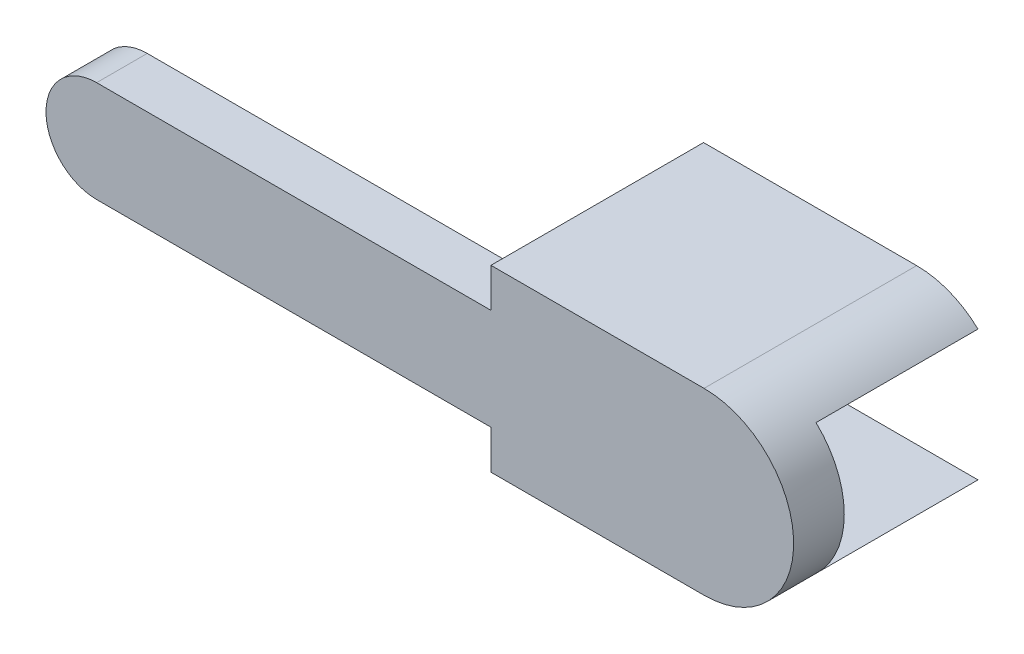
from build123d import *

# Parameters (mm, degrees)
BOSS_EXTRUDE1_DEPTH = 5
SKETCH2_R           = 2.35
CUT_EXTRUDE1_DEPTH  = 3
BOSS_EXTRUDE3_DEPTH = 5
BOSS_EXTRUDE4_DEPTH = 16
SKETCH5_R           = 1.025
CUT_EXTRUDE2_DEPTH  = 5


with BuildPart() as part:
    # Sketch1 → Boss-Extrude1 (new body)
    with BuildSketch(Plane.XY):
        with BuildLine():
            Line((0, 5), (60, 5))
            ThreePointArc((60, 5), (65, 0), (60, -5))
            Line((60, -5), (0, -5))
            ThreePointArc((0, -5), (-5, 0), (0, 5))
        make_face()
    extrude(amount=BOSS_EXTRUDE1_DEPTH)

    # Sketch2 → Cut-Extrude1 (cut)
    with BuildSketch(Plane(origin=(0, 0, 0), x_dir=(-1, 0, 0), z_dir=(0, 0, -1))):
        Circle(SKETCH2_R)
    extrude(amount=-CUT_EXTRUDE1_DEPTH, mode=Mode.SUBTRACT)

    # Sketch3 → Boss-Extrude3 (add)
    with BuildSketch(Plane.XY.offset(5)):
        with BuildLine():
            Line((38.95, -6.35), (38.95, 6.35))
            Line((38.95, 6.35), (38.95, 8.85))
            Line((38.95, 8.85), (60, 8.85))
            ThreePointArc((60, 8.85), (68.85, 0), (60, -8.85))
            Line((60, -8.85), (38.95, -8.85))
            Line((38.95, -8.85), (38.95, -6.35))
        make_face()
    extrude(amount=-BOSS_EXTRUDE3_DEPTH)

    # Sketch4 → Boss-Extrude4 (add)
    with BuildSketch(Plane(origin=(0, 0, 0), x_dir=(-1, 0, 0), z_dir=(0, 0, -1))):
        with BuildLine():
            Line((-60, 8.85), (-38.95, 8.85))
            Line((-38.95, 8.85), (-38.95, 5))
            Line((-38.95, 5), (-38.95, -5))
            Line((-38.95, -5), (-38.95, -8.85))
            Line((-38.95, -8.85), (-60, -8.85))
            ThreePointArc((-60, -8.85), (-63.258834147, -8.228152891), (-66.059702963, -6.45))
            Line((-66.059702963, -6.45), (-43.45, -6.45))
            Line((-43.45, -6.45), (-43.45, 6.45))
            Line((-43.45, 6.45), (-66.059702963, 6.45))
            ThreePointArc((-66.059702963, 6.45), (-63.258834147, 8.228152891), (-60, 8.85))
        make_face()
    extrude(amount=BOSS_EXTRUDE4_DEPTH)

    # Sketch5 → Cut-Extrude2 (cut)
    with BuildSketch(Plane(origin=(0, 0, -16), x_dir=(-1, 0, 0), z_dir=(0, 0, -1))):
        with Locations((-41.25, 0)):
            Circle(SKETCH5_R)
    extrude(amount=-CUT_EXTRUDE2_DEPTH, mode=Mode.SUBTRACT)


solid = part.part
